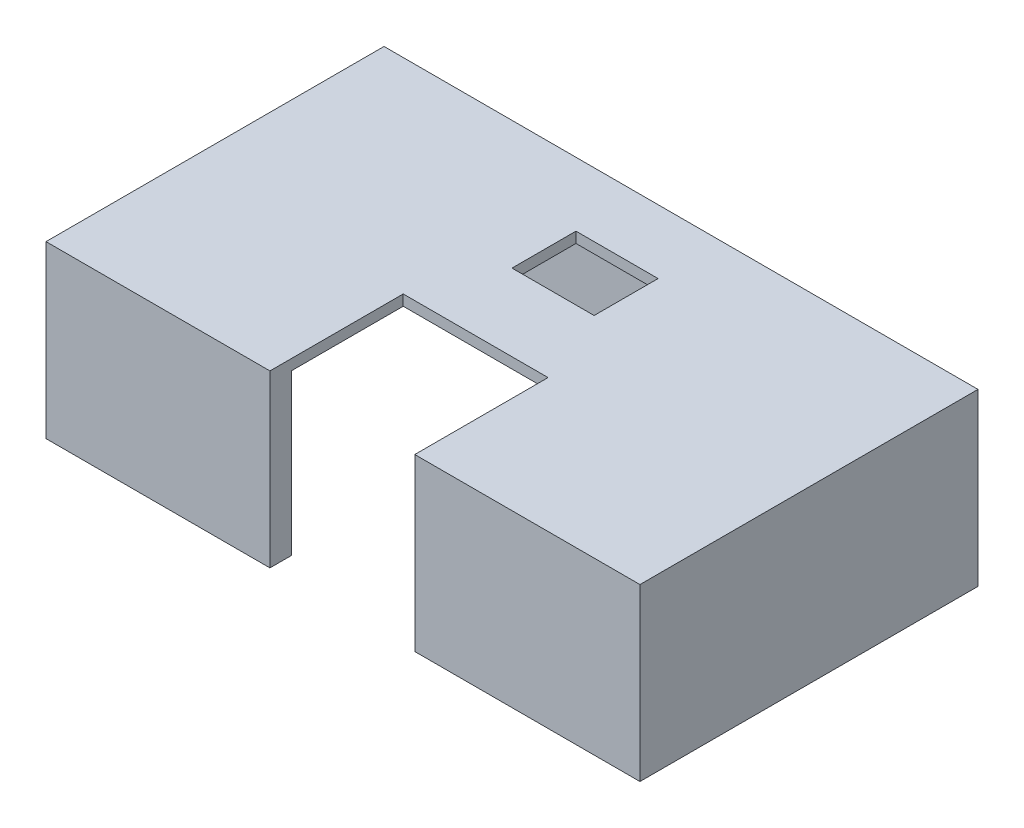
from build123d import *

# Parameters (mm, degrees)
SKETCH1_W           = 55.7
SKETCH1_H           = 31.7
BOSS_EXTRUDE1_DEPTH = 16
SKETCH3_W           = 51.7
SKETCH3_H           = 27.7
CUT_EXTRUDE2_DEPTH  = 15
CUT_EXTRUDE3_START  = -5
SKETCH4_W           = 13.581579568
SKETCH4_H           = 13.316801047
CUT_EXTRUDE3_DEPTH  = 21
SKETCH5_W           = 7.7
SKETCH5_H           = 6
CUT_EXTRUDE4_DEPTH  = 10
SKETCH7_W           = 13.7
SKETCH7_H           = 14.99631632
CUT_EXTRUDE5_DEPTH  = 10


with BuildPart() as part:
    # Sketch1 → Boss-Extrude1 (new body)
    with BuildSketch(Plane(origin=(0, 0, 0), x_dir=(1, 0, 0), z_dir=(0, 1, 0))):
        with Locations((27.85, 15.85)):
            Rectangle(SKETCH1_W, SKETCH1_H)
    extrude(amount=BOSS_EXTRUDE1_DEPTH)

    # Sketch3 → Cut-Extrude2 (cut)
    with BuildSketch(Plane.XZ):
        with Locations((27.85, -15.85)):
            Rectangle(SKETCH3_W, SKETCH3_H)
    extrude(amount=-CUT_EXTRUDE2_DEPTH, mode=Mode.SUBTRACT)

    # Sketch4 → Cut-Extrude3 (cut, through all)
    with BuildSketch(Plane.XZ.offset(-15).offset(CUT_EXTRUDE3_START)):
        with Locations((27.790789784, -5.841599476)):
            Rectangle(SKETCH4_W, SKETCH4_H)
    extrude(amount=CUT_EXTRUDE3_DEPTH, mode=Mode.SUBTRACT)

    # Sketch5 → Cut-Extrude4 (cut)
    with BuildSketch(Plane.XZ.offset(-15)):
        with Locations((27.85, -22.7)):
            Rectangle(SKETCH5_W, SKETCH5_H)
    extrude(amount=-CUT_EXTRUDE4_DEPTH, mode=Mode.SUBTRACT)

    # Sketch7 → Cut-Extrude5 (cut)
    with BuildSketch(Plane.ZY):
        with Locations((-15.85, 6.784922937)):
            Rectangle(SKETCH7_W, SKETCH7_H)
    extrude(amount=-CUT_EXTRUDE5_DEPTH, mode=Mode.SUBTRACT)


solid = part.part
